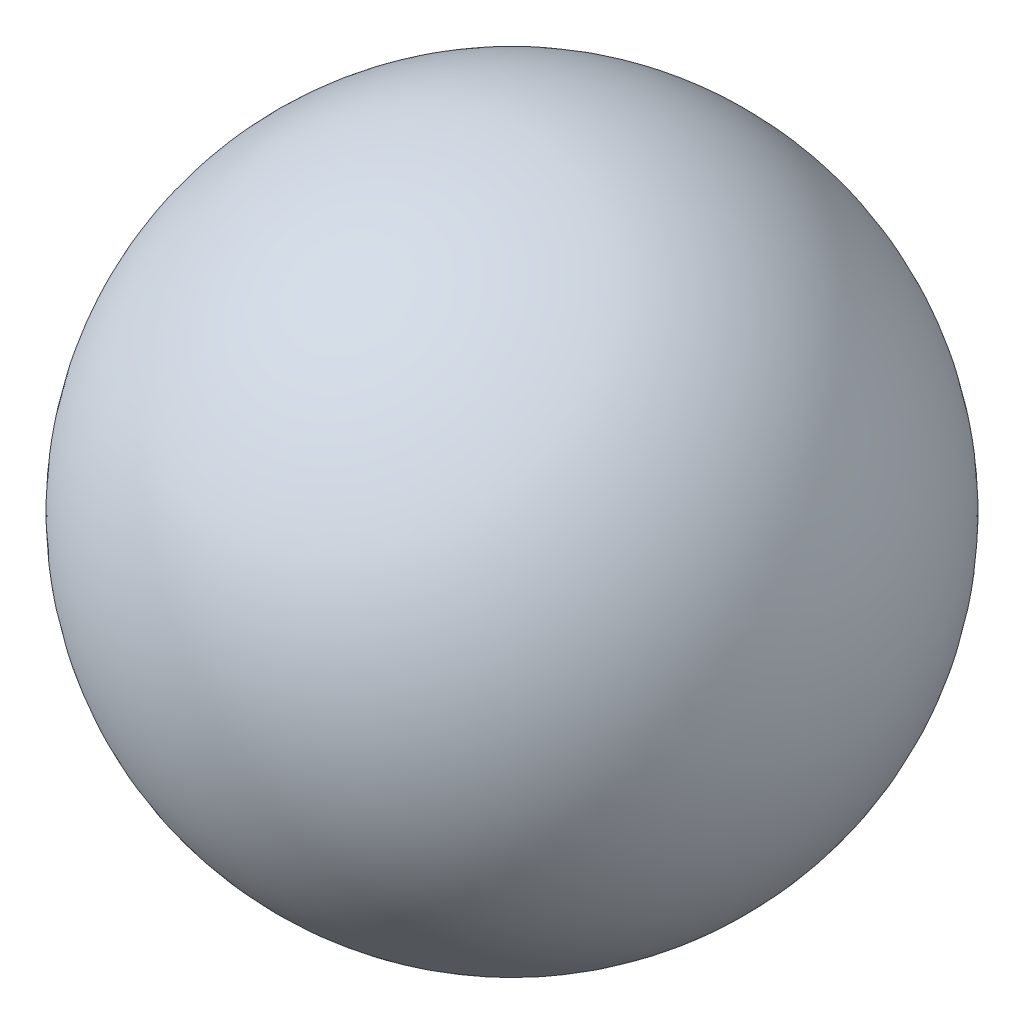
from build123d import *


with BuildPart() as part:
    # Sketch3 → Revolve1 (revolve)
    with BuildSketch(Plane.XY):
        with BuildLine():
            Line((0, -76.2), (0, 76.2))
            ThreePointArc((0, 76.2), (-76.362388974, 0), (0, -76.2))
        make_face()
    revolve(axis=Axis((0, -76.2, 0), (0, 1, 0)))


solid = part.part
